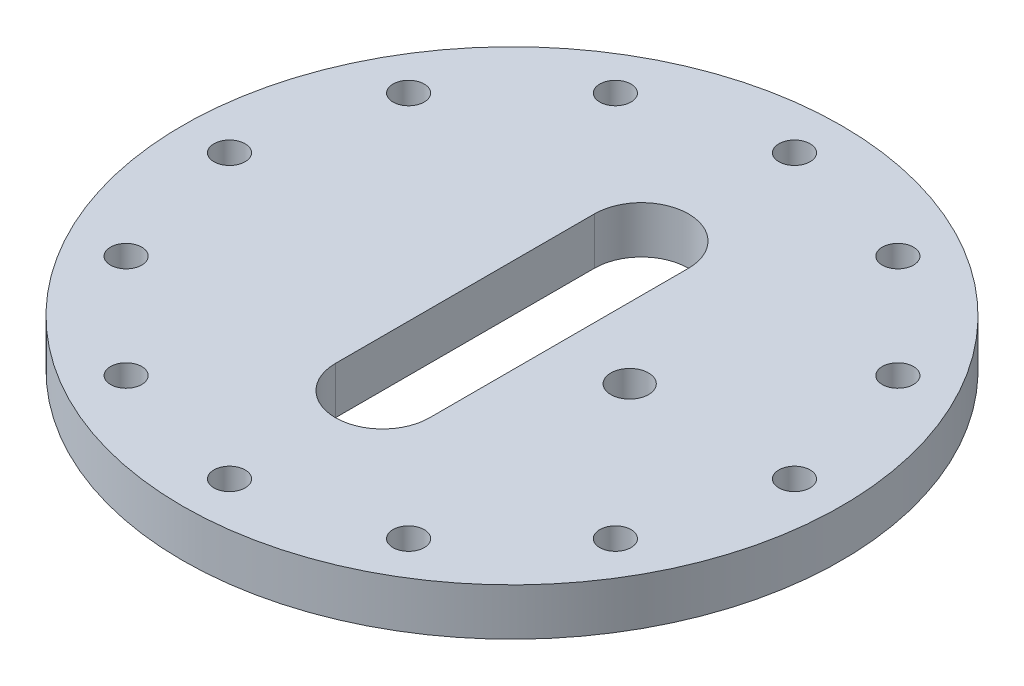
from build123d import *

# Parameters (mm, degrees)
SKETCH2_W                = 88.9
SKETCH2_H                = 12.7
CUT_EXTRUDE1_DEPTH       = 127.363404513
F_5_16_CLEARANCE_HOLE1_D = 8.4328
CIRPATTERN1_COUNT        = 12
F_5_16_CLEARANCE_HOLE2_D = 10.16


with BuildPart() as part:
    # Sketch2 → Revolve1 (revolve)
    with BuildSketch(Plane.XY):
        with Locations((-44.45, 6.35)):
            Rectangle(SKETCH2_W, SKETCH2_H)
    revolve(axis=Axis((0, 12.7, 0), (0, -1, 0)))

    # Sketch3 → Cut-Extrude1 (cut, through all)
    with BuildSketch(Plane(origin=(0, 12.7, 0), x_dir=(1, 0, 0), z_dir=(0, 1, 0))):
        with BuildLine():
            Line((-12.7, 34.925), (-12.7, -34.925))
            ThreePointArc((-12.7, -34.925), (0, -47.625), (12.7, -34.925))
            Line((12.7, -34.925), (12.7, 34.925))
            ThreePointArc((12.7, 34.925), (0, 47.625), (-12.7, 34.925))
        make_face()
    extrude(amount=-CUT_EXTRUDE1_DEPTH, mode=Mode.SUBTRACT)

    # 5_16 Clearance Hole1 (through all)
    with Locations(Plane(origin=(0, 12.7, 0), x_dir=(1, 0, 0), z_dir=(0, 1, 0))):
        with Locations((0, 76.2)):
            f_5_16_clearance_hole1 = Hole(F_5_16_CLEARANCE_HOLE1_D / 2)

    # CirPattern1: 5_16 Clearance Hole1 ×12 about axis
    cirpattern1_axis = Axis((0, 13.335, 0), (0, -1, 0))
    for i in range(1, CIRPATTERN1_COUNT):
        add(f_5_16_clearance_hole1.rotate(cirpattern1_axis, i * 360 / CIRPATTERN1_COUNT), mode=Mode.SUBTRACT)

    # 5_16 Clearance Hole2 (through all)
    with Locations(Plane(origin=(0, 12.7, 0), x_dir=(1, 0, 0), z_dir=(0, 1, 0))):
        with Locations((31.75, 0)):
            Hole(F_5_16_CLEARANCE_HOLE2_D / 2)


solid = part.part
